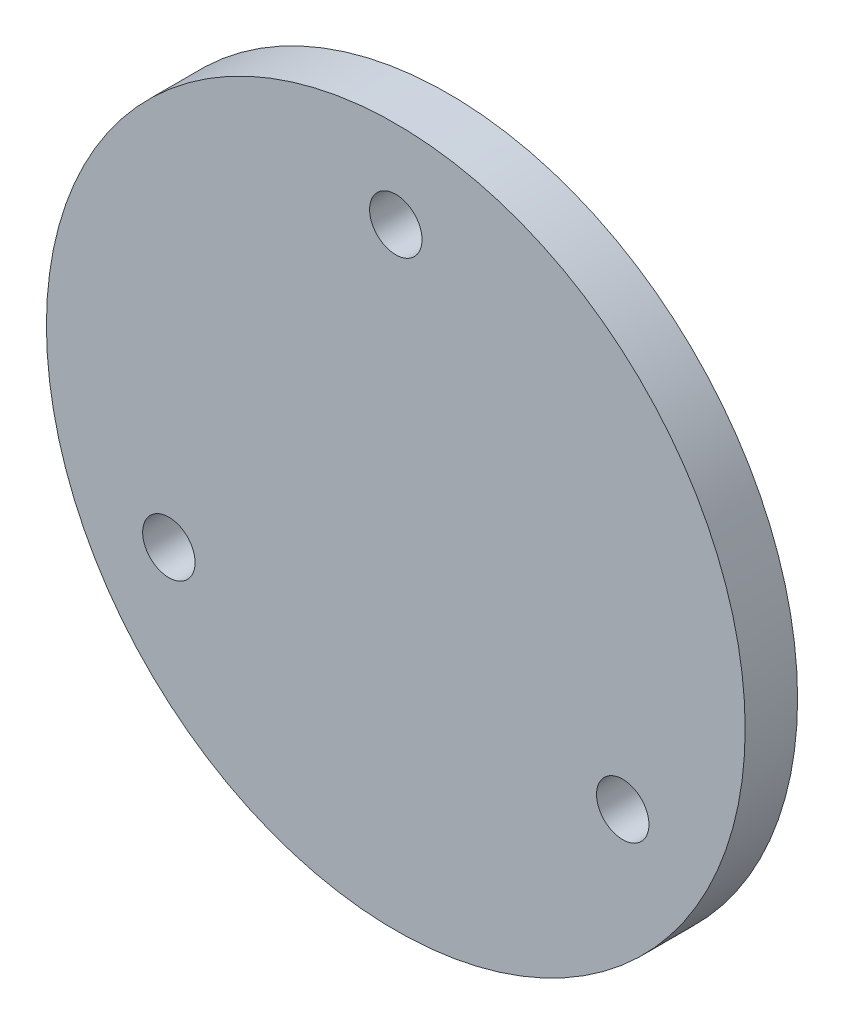
from build123d import *

# Parameters (mm, degrees)
SKETCH1_R           = 20
SKETCH1_R_2         = 1.5
BOSS_EXTRUDE1_DEPTH = 3


with BuildPart() as part:
    # Sketch1 → Boss-Extrude1 (new body)
    with BuildSketch(Plane.XY):
        Circle(SKETCH1_R)
        with Locations((0, 15)):
            Circle(SKETCH1_R_2, mode=Mode.SUBTRACT)
        with Locations((-12.990381057, -7.5)):
            Circle(SKETCH1_R_2, mode=Mode.SUBTRACT)
        with Locations((12.990381057, -7.5)):
            Circle(SKETCH1_R_2, mode=Mode.SUBTRACT)
    extrude(amount=BOSS_EXTRUDE1_DEPTH)


solid = part.part
